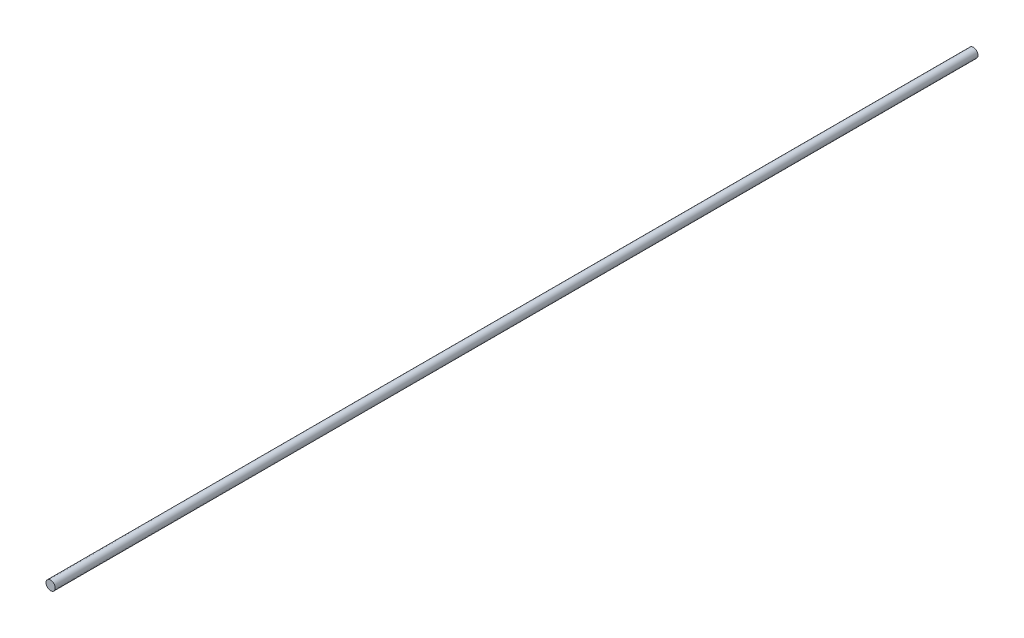
from build123d import *

# Parameters (mm, degrees)
SKETCH1_R           = 1
BOSS_EXTRUDE1_DEPTH = 200


with BuildPart() as part:
    # Sketch1 → Boss-Extrude1 (new body)
    with BuildSketch(Plane.XY):
        Circle(SKETCH1_R)
    extrude(amount=BOSS_EXTRUDE1_DEPTH)


solid = part.part
